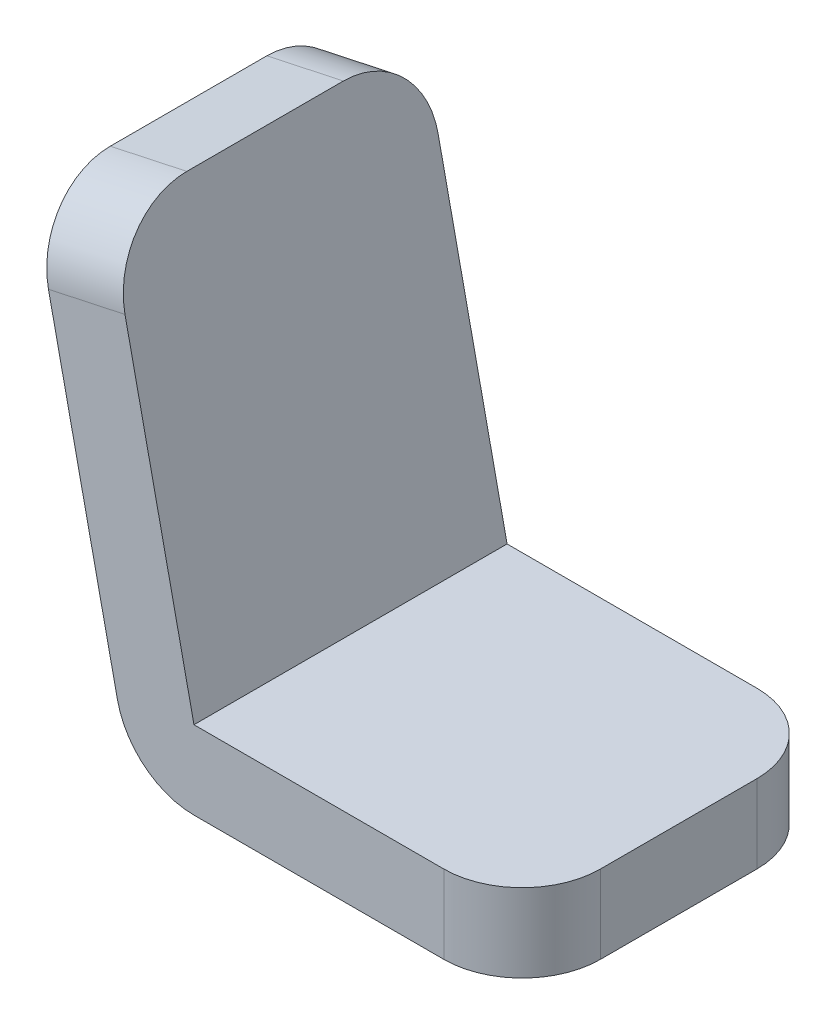
from build123d import *

# Parameters (mm, degrees)
EXTRUDE_THIN1_DEPTH = 40
FILLET1_R           = 10
FILLET2_R           = 10
FILLET3_R           = 10
FILLET4_R           = 10


with BuildPart() as part:
    # Sketch1 → Extrude-Thin1 (new body)
    with BuildSketch(Plane.XY):
        with BuildLine():
            Line((50, 0), (8.078800395, 0))
            ThreePointArc((8.078800395, 0), (1.794545597, 2.221302061), (-1.697863575, 7.898371675))
            Line((-1.697863575, 7.898371675), (-12.609769953, 58.65998382))
            Line((-12.609769953, 58.65998382), (-2.833105983, 60.761612145))
            Line((-2.833105983, 60.761612145), (8.078800395, 10))
            Line((8.078800395, 10), (50, 10))
            Line((50, 10), (50, 0))
        make_face()
    extrude(amount=EXTRUDE_THIN1_DEPTH)

    # Fillet1
    fillet1_edges = [part.edges().sort_by_distance(p)[0] for p in [
        (-7.721437968, 59.710797982, 40),
    ]]
    fillet(fillet1_edges, radius=FILLET1_R)

    # Fillet2
    fillet2_edges = [part.edges().sort_by_distance(p)[0] for p in [
        (50, 5, 40),
    ]]
    fillet(fillet2_edges, radius=FILLET2_R)

    # Fillet3
    fillet3_edges = [part.edges().sort_by_distance(p)[0] for p in [
        (50, 5, 0),
    ]]
    fillet(fillet3_edges, radius=FILLET3_R)

    # Fillet4
    fillet4_edges = [part.edges().sort_by_distance(p)[0] for p in [
        (-7.721437968, 59.710797982, 0),
    ]]
    fillet(fillet4_edges, radius=FILLET4_R)


solid = part.part
